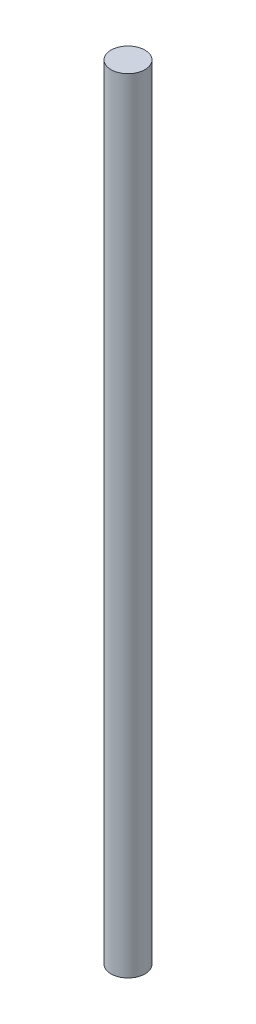
from build123d import *

# Parameters (mm, degrees)
SKETCH1_R           = 1.8415
BOSS_EXTRUDE1_DEPTH = 84.963


with BuildPart() as part:
    # Sketch1 → Boss-Extrude1 (new body)
    with BuildSketch(Plane(origin=(0, 0, 0), x_dir=(1, 0, 0), z_dir=(0, 1, 0))):
        Circle(SKETCH1_R)
    extrude(amount=BOSS_EXTRUDE1_DEPTH)


solid = part.part
